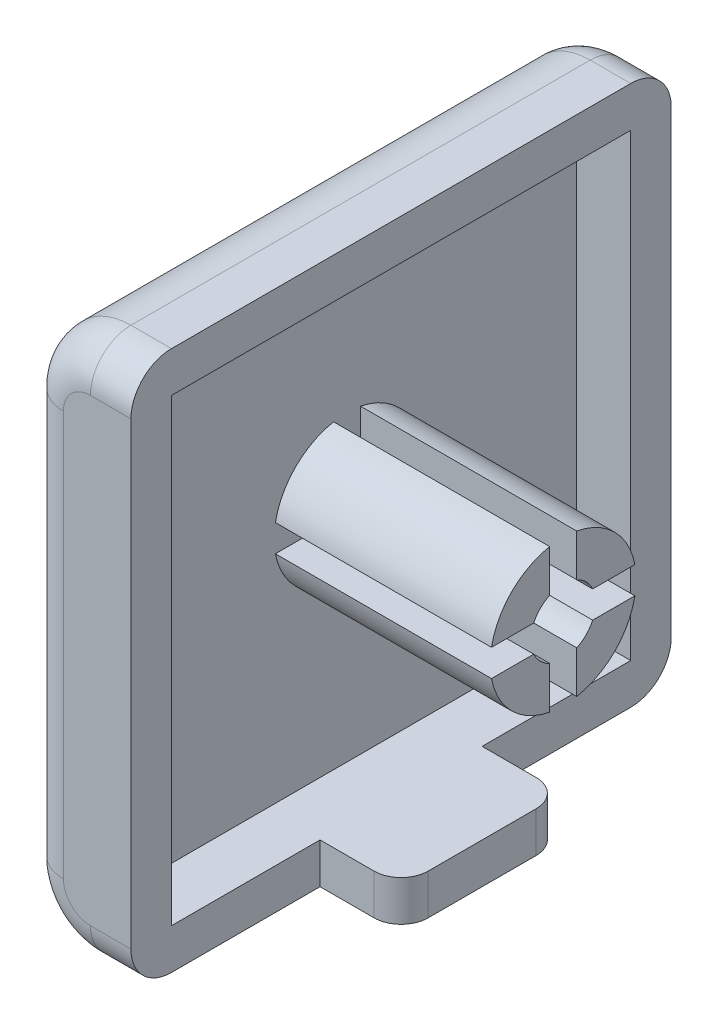
from build123d import *

# Parameters (mm, degrees)
EXTRUDE_3_DEPTH      = 10
EXTRUDE_3_DEPTH_BACK = 10
FILLET_3_R           = 1.5
SKETCH_6_W           = 17
SKETCH_6_H           = 17
CUT_EXTRUDE_2_DEPTH  = 2
SKETCH_9_W           = 6
SKETCH_9_H           = 1.5
EXTRUDE_6_DEPTH      = 3
EXTRUDE_7_DEPTH      = 8
FILLET_4_R           = 1


with BuildPart() as part:
    # Sketch 3 → Extrude 3 (new body, two sides)
    with BuildSketch(Plane.XY) as extrude_3_sk:
        with BuildLine():
            Line((0.5, -10), (2, -10))
            Line((2, -10), (2, 10))
            Line((2, 10), (0.5, 10))
            ThreePointArc((0.5, 10), (-1.267766953, 9.267766953), (-2, 7.5))
            Line((-2, 7.5), (-2, -7.5))
            ThreePointArc((-2, -7.5), (-1.267766953, -9.267766953), (0.5, -10))
        make_face()
    extrude(amount=EXTRUDE_3_DEPTH)
    extrude(extrude_3_sk.sketch, amount=-EXTRUDE_3_DEPTH_BACK)

    # Fillet 3
    fillet_3_edges = [part.edges().sort_by_distance(p)[0] for p in [
        (-1.267766953, 9.267766953, -10),
        (-2, 0, -10),
        (1.25, 10, 10),
        (-1.267766953, 9.267766953, 10),
        (-2, 0, 10),
        (-1.267766953, -9.267766953, 10),
        (1.25, -10, 10),
        (-1.267766953, -9.267766953, -10),
        (1.25, -10, -10),
        (1.25, 10, -10),
    ]]
    fillet(fillet_3_edges, radius=FILLET_3_R)

    # Sketch 6 → Cut-Extrude 2 (cut)
    with BuildSketch(Plane(origin=(2, 0, 0), x_dir=(0, 0, -1), z_dir=(1, 0, 0))):
        Rectangle(SKETCH_6_W, SKETCH_6_H)
    extrude(amount=-CUT_EXTRUDE_2_DEPTH, mode=Mode.SUBTRACT)

    # Sketch 9 → Extrude 6 (add)
    with BuildSketch(Plane(origin=(2, 0, 0), x_dir=(0, 0, -1), z_dir=(1, 0, 0))):
        with Locations((0, -9.25)):
            Rectangle(SKETCH_9_W, SKETCH_9_H)
    extrude(amount=EXTRUDE_6_DEPTH)

    # Sketch 10 → Extrude 7 (add)
    with BuildSketch(Plane(origin=(0, 0, 0), x_dir=(0, 0, -1), z_dir=(1, 0, 0))):
        with BuildLine():
            Line((-0.5, 2.653299832), (-0.5, 1.090871211))
            ThreePointArc((-0.5, 1.090871211), (-0.848528137, 0.848528137), (-1.090871211, 0.5))
            Line((-1.090871211, 0.5), (-2.653299832, 0.5))
            ThreePointArc((-2.653299832, 0.5), (-1.909188309, 1.909188309), (-0.5, 2.653299832))
        make_face()
        with BuildLine():
            Line((0.5, 2.653299832), (0.5, 1.090871211))
            ThreePointArc((0.5, 1.090871211), (0.848528137, 0.848528137), (1.090871211, 0.5))
            Line((1.090871211, 0.5), (2.653299832, 0.5))
            ThreePointArc((2.653299832, 0.5), (1.909188309, 1.909188309), (0.5, 2.653299832))
        make_face()
        with BuildLine():
            Line((-2.653299832, -0.5), (-1.090871211, -0.5))
            ThreePointArc((-1.090871211, -0.5), (-0.848528137, -0.848528137), (-0.5, -1.090871211))
            Line((-0.5, -1.090871211), (-0.5, -2.653299832))
            ThreePointArc((-0.5, -2.653299832), (-1.909188309, -1.909188309), (-2.653299832, -0.5))
        make_face()
        with BuildLine():
            Line((0.5, -1.090871211), (0.5, -2.653299832))
            ThreePointArc((0.5, -2.653299832), (1.909188309, -1.909188309), (2.653299832, -0.5))
            Line((2.653299832, -0.5), (1.090871211, -0.5))
            ThreePointArc((1.090871211, -0.5), (0.848528137, -0.848528137), (0.5, -1.090871211))
        make_face()
    extrude(amount=EXTRUDE_7_DEPTH)

    # Fillet 4
    fillet_4_edges = [part.edges().sort_by_distance(p)[0] for p in [
        (5, -9.25, 3),
        (5, -9.25, -3),
    ]]
    fillet(fillet_4_edges, radius=FILLET_4_R)


solid = part.part
